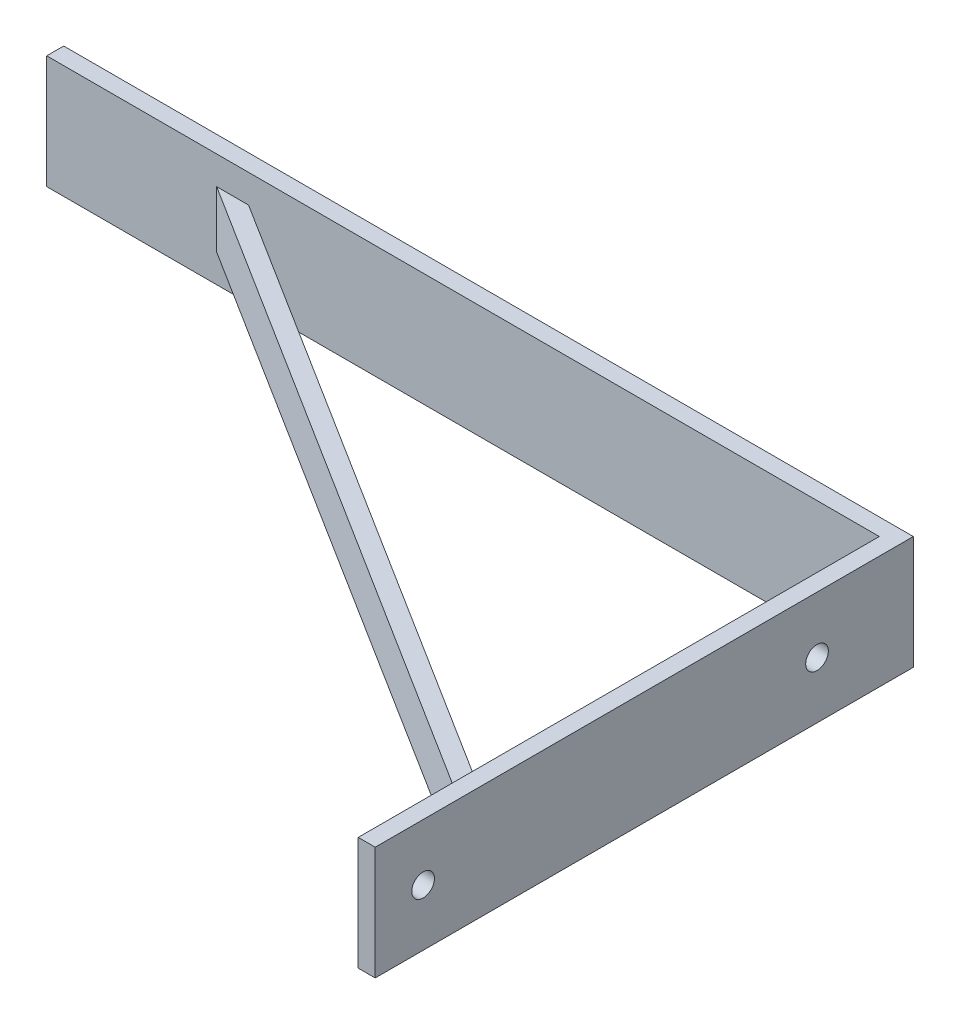
from build123d import *

# Parameters (mm, degrees)
SALIENTE_EXTRUIR1_DEPTH = 20
CROQUIS2_R              = 2
CORTAR_EXTRUIR1_DEPTH   = 20
CORTAR_EXTRUIR2_DEPTH   = 5
CORTAR_EXTRUIR3_DEPTH   = 5


with BuildPart() as part:
    # Croquis1 → Saliente-Extruir1 (new body)
    with BuildSketch(Plane(origin=(0, 0, 0), x_dir=(1, 0, 0), z_dir=(0, 1, 0))):
        Polygon((3, -92), (3, 3), (-147, 3), (-147, 0), (0, 0), (0, -92), align=None)
        Polygon((-111.362752101, 0), (-117, 0), (0, -73.543441101), (0, -70), align=None)
    extrude(amount=SALIENTE_EXTRUIR1_DEPTH)

    # Croquis2 → Cortar-Extruir1 (cut)
    with BuildSketch(Plane.ZY):
        with Locations((83.543441101, 10)):
            Circle(CROQUIS2_R)
        with Locations((14, 10)):
            Circle(CROQUIS2_R)
    extrude(amount=-CORTAR_EXTRUIR1_DEPTH, mode=Mode.SUBTRACT)

    # Croquis3 → Cortar-Extruir2 (cut)
    with BuildSketch(Plane.XZ):
        Polygon((0, 70), (0, 73.543441101), (-117, 0), (-111.362752101, 0), align=None)
    extrude(amount=-CORTAR_EXTRUIR2_DEPTH, mode=Mode.SUBTRACT)

    # Croquis4 → Cortar-Extruir3 (cut)
    with BuildSketch(Plane(origin=(0, 20, 0), x_dir=(1, 0, 0), z_dir=(0, 1, 0))):
        Polygon((0, -73.543441101), (0, -70), (-111.362752101, 0), (-117, 0), align=None)
    extrude(amount=-CORTAR_EXTRUIR3_DEPTH, mode=Mode.SUBTRACT)


solid = part.part
